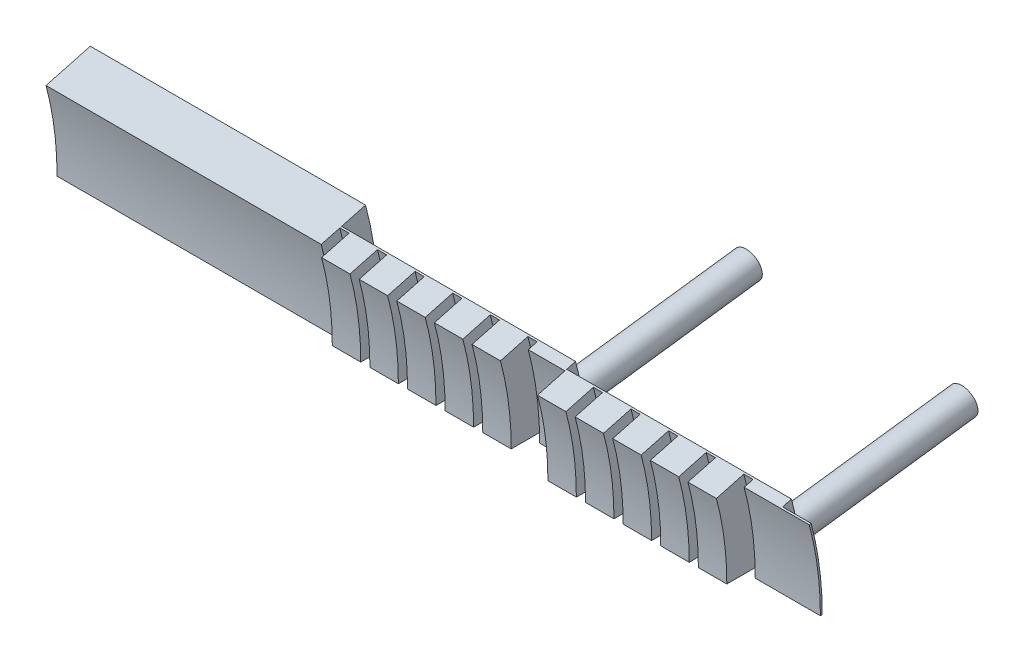
from build123d import *

# Parameters (mm, degrees)
REVOLVE1_ANGLE           = 15
SKETCH2_R                = 0.3937
BOSS_EXTRUDE2_DEPTH      = 5.08
BOSS_EXTRUDE2_DEPTH_BACK = 0.127
BOSS_EXTRUDE3_START      = -0.008318
SKETCH3_R                = 0.3937
BOSS_EXTRUDE3_DEPTH      = 5.088318


with BuildPart() as part:
    # Sketch1 → Revolve1 (revolve)
    with BuildSketch(Plane(origin=(0, 0, 0), x_dir=(1, 0, 0), z_dir=(0, 1, 0))):
        Polygon((0.254, 9.525), (0.254, 8.7376), (1.0414, 8.7376), (1.0414, 9.525), (1.2954, 9.525), (1.2954, 8.7376), (2.0828, 8.7376), (2.0828, 9.525), (2.3368, 9.525), (2.3368, 8.7376), (3.1242, 8.7376), (3.1242, 9.525), (3.3782, 9.525), (3.3782, 8.7376), (4.1656, 8.7376), (4.1656, 9.525), (4.4196, 9.525), (4.4196, 8.7376), (5.207, 8.7376), (5.207, 9.525), (5.461, 9.525), (5.461, 9.271), (6.477, 9.271), (6.477, 8.4836), (7.2644, 8.4836), (7.2644, 9.271), (7.5184, 9.271), (7.5184, 8.4836), (8.3058, 8.4836), (8.3058, 9.271), (8.5598, 9.271), (8.5598, 8.4836), (9.3472, 8.4836), (9.3472, 9.271), (9.6012, 9.271), (9.6012, 8.4836), (10.3886, 8.4836), (10.3886, 9.271), (10.6426, 9.271), (10.6426, 8.4836), (11.43, 8.4836), (11.43, 9.271), (11.684, 9.271), (11.684, 9.017), (12.7, 9.017), (13.4874, 9.017), (13.4874, 9.0678), (12.7, 9.0678), (12.7, 9.3218), (6.477, 9.3218), (6.477, 9.5758), (0, 9.5758), (0, 10.2616), (-7.62, 10.2616), (-7.62, 8.9916), (0, 8.9916), (0, 9.525), align=None)
    revolve(axis=Axis((0, 0, 0), (1, 0, 0)), revolution_arc=REVOLVE1_ANGLE)

    # Sketch3 → Boss-Extrude3 (add)
    with BuildSketch(Plane(origin=(0, 1.216739059, -9.242050709), x_dir=(-1, 0, 0), z_dir=(0, 0.130526192, -0.991444861)).offset(BOSS_EXTRUDE3_START)):
        with Locations((-12.192, 0)):
            Circle(SKETCH3_R)
    extrude(amount=BOSS_EXTRUDE3_DEPTH)


with BuildPart() as body_2:
    # Sketch2 → Boss-Extrude2 (new body, two sides)
    with BuildSketch(Plane(origin=(0, 1.249892711, -9.493877704), x_dir=(-1, 0, 0), z_dir=(0, 0.130526192, -0.991444861))) as boss_extrude2_sk:
        with Locations((-5.969, 0)):
            Circle(SKETCH2_R)
    extrude(amount=BOSS_EXTRUDE2_DEPTH)
    extrude(boss_extrude2_sk.sketch, amount=-BOSS_EXTRUDE2_DEPTH_BACK)


solid = Compound([part.part, body_2.part])
